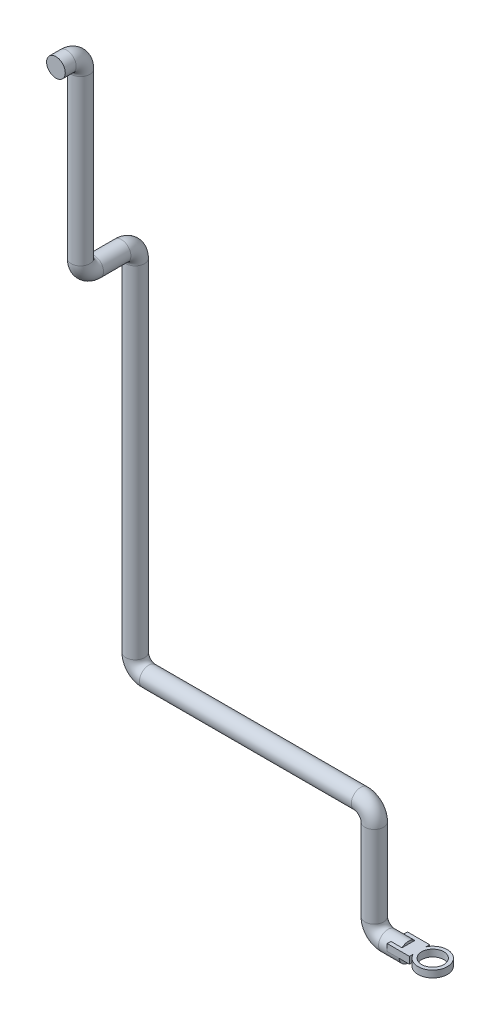
from build123d import *

# Parameters (mm, degrees)
CROQUIS1_R              = 13.7
CROQUIS2_R              = 21.4730032
CROQUIS2_R_2            = 16.237273766
SALIENTE_EXTRUIR1_DEPTH = 10


with BuildPart() as part:
    # Barrer1: sweep along a curve in space
    with BuildLine() as barrer1_path:
        Line((0, 0, 0), (-30, 0, 0))
        ThreePointArc((-30, 0, 0), (-44.142135624, 5.857864376, 0), (-50, 20, 0))
        Line((-50, 20, 0), (-50, 140, 0))
        ThreePointArc((-50, 140, 0), (-55.857864376, 154.142135624, 0), (-70, 160, 0))
        Line((-70, 160, 0), (-380, 160, 0))
        ThreePointArc((-380, 160, 0), (-394.142135624, 165.857864376, 0), (-400, 180, 0))
        Line((-400, 180, 0), (-400, 679.4, 0))
        ThreePointArc((-400, 679.4, 0), (-400, 693.542135624, 5.857864376), (-400, 699.4, 20))
        Line((-400, 699.4, 20), (-400, 699.4, 60))
        ThreePointArc((-400, 699.4, 60), (-400, 705.257864376, 74.142135624), (-400, 719.4, 80))
        Line((-400, 719.4, 80), (-400, 959.4, 80))
        ThreePointArc((-400, 959.4, 80), (-400, 973.542135624, 85.857864376), (-400, 979.4, 100))
        Line((-400, 979.4, 100), (-400, 979.4, 116))
    # Croquis1 → Barrer1 (sweep)
    with BuildSketch(Plane(origin=(0, 0, 0), x_dir=(0, 0, -1), z_dir=(1, 0, 0))):
        Circle(CROQUIS1_R)
    sweep(path=barrer1_path.line)

    # Croquis2 → Saliente-Extruir1 (add)
    with BuildSketch(Plane(origin=(0, 0, 0), x_dir=(1, 0, 0), z_dir=(0, 1, 0))):
        with BuildLine():
            Line((16.265932776, -14.786933088), (16.265932776, -9.412377025))
            ThreePointArc((16.265932776, -9.412377025), (14.093111574, 0), (16.265932776, 9.412377025))
            Line((16.265932776, 9.412377025), (16.265932776, 14.786933088))
            Line((16.265932776, 14.786933088), (-16.265932776, 14.786933088))
            Line((-16.265932776, 14.786933088), (-16.265932776, -14.786933088))
            Line((-16.265932776, -14.786933088), (16.265932776, -14.786933088))
        make_face()
        with Locations((35.566114774, 0)):
            Circle(CROQUIS2_R)
        with Locations((35.566114774, 0)):
            Circle(CROQUIS2_R_2, mode=Mode.SUBTRACT)
    extrude(amount=SALIENTE_EXTRUIR1_DEPTH)


solid = part.part
